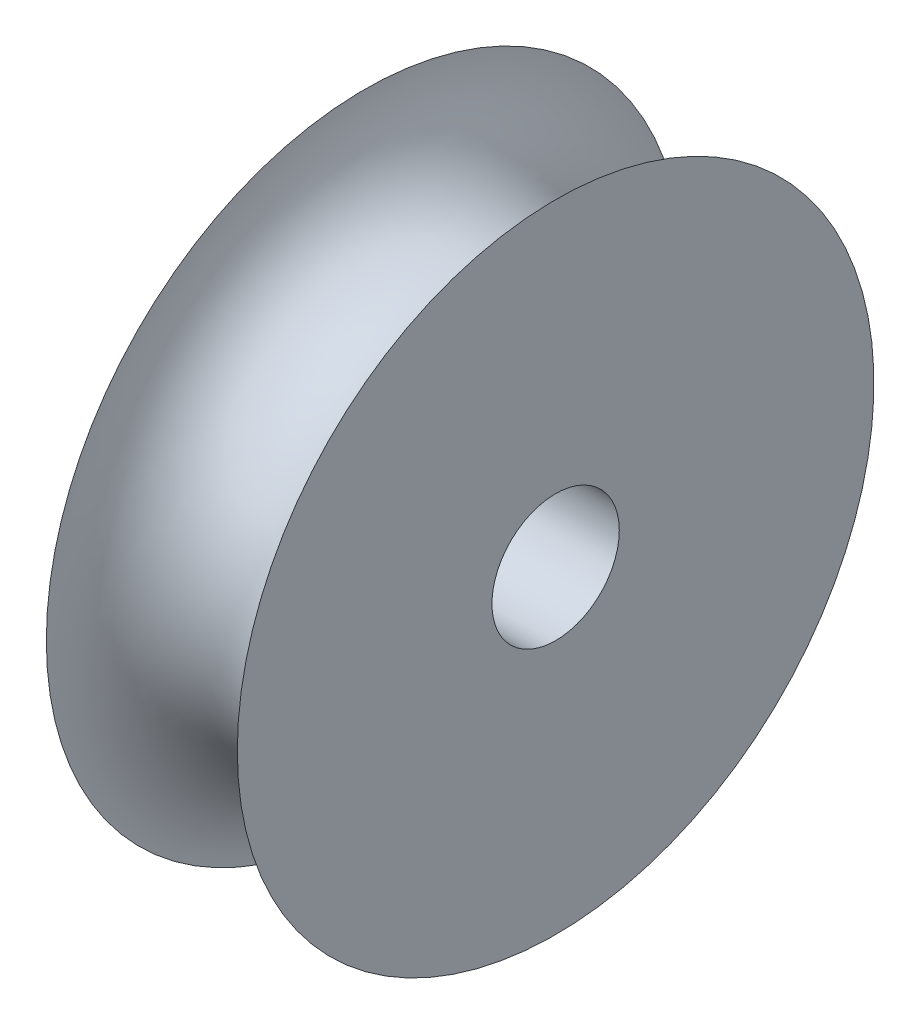
from build123d import *

# Parameters (mm, degrees)
SKETCH2_R          = 3.175
CUT_EXTRUDE1_DEPTH = 10.525


with BuildPart() as part:
    # Sketch1 → Revolve1 (revolve)
    with BuildSketch(Plane.XY):
        with BuildLine():
            Line((0, 15.875), (0, 0))
            Line((0, 0), (9.525, 0))
            Line((9.525, 0), (9.525, 15.875))
            ThreePointArc((9.525, 15.875), (4.7625, 11.1125), (0, 15.875))
        make_face()
    revolve(axis=Axis((0, 0, 0), (1, 0, 0)))

    # Sketch2 → Cut-Extrude1 (cut, through all)
    with BuildSketch(Plane(origin=(9.525, 0, 0), x_dir=(0, 0, -1), z_dir=(1, 0, 0))):
        Circle(SKETCH2_R)
    extrude(amount=-CUT_EXTRUDE1_DEPTH, mode=Mode.SUBTRACT)


solid = part.part
